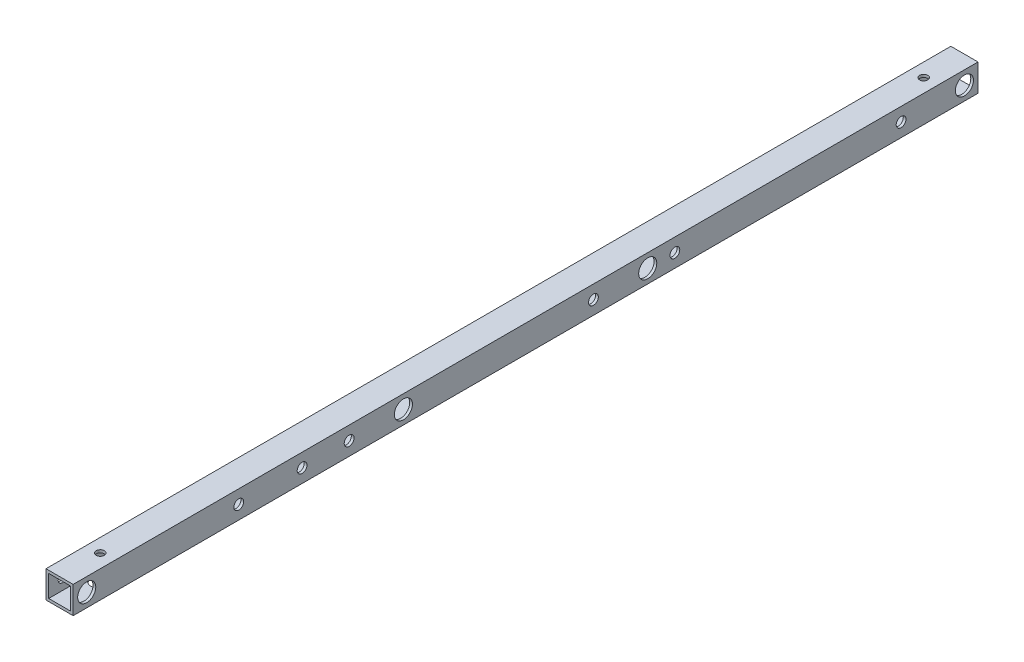
from build123d import *

# Parameters (mm, degrees)
SKETCH_1_W                  = 15
SKETCH_1_H                  = 15
SKETCH_1_W_2                = 12
SKETCH_1_H_2                = 12
EXTRUDE_1_DEPTH             = 500
SKETCH_2_R                  = 2.25
CUT_EXTRUDE_1_DEPTH         = 25
SKETCH_4_R                  = 2.25
CUT_EXTRUDE_3_DEPTH         = 20
SKETCH_5_R                  = 5
CUT_EXTRUDE_4_DEPTH         = 3.3
SKETCH_6_R                  = 5
CUT_EXTRUDE_5_DEPTH         = 3.3
HOLE_WIZARD_5_4_5_4_1_D     = 5.4
HOLE_WIZARD_10_0_10_1_D     = 10
HOLE_WIZARD_10_0_10_1_DEPTH = 1.5
HOLE_WIZARD_10_0_10_1_TIP   = 3.004303095


with BuildPart() as part:
    # ｽｹｯﾁ1 → ﾎﾞｽ - 押し出し1 (new body)
    with BuildSketch(Plane.XY):
        Rectangle(SKETCH_1_W, SKETCH_1_H)
        Rectangle(SKETCH_1_W_2, SKETCH_1_H_2, mode=Mode.SUBTRACT)
    extrude(amount=EXTRUDE_1_DEPTH)

    # ｽｹｯﾁ2 → ｶｯﾄ - 押し出し1 (cut)
    with BuildSketch(Plane(origin=(7.5, 0, 0), x_dir=(0, 0, -1), z_dir=(1, 0, 0))):
        with Locations((-492.5, 0)):
            Circle(SKETCH_2_R)
        with Locations((-7.5, 0)):
            Circle(SKETCH_2_R)
        with Locations((-317.5, 0)):
            Circle(SKETCH_2_R)
        with Locations((-182.5, 0)):
            Circle(SKETCH_2_R)
    extrude(amount=-CUT_EXTRUDE_1_DEPTH, mode=Mode.SUBTRACT)

    # ｽｹｯﾁ4 → ｶｯﾄ - 押し出し3 (cut)
    with BuildSketch(Plane(origin=(0, -7.5, 0), x_dir=(-1, 0, 0), z_dir=(0, -1, 0))):
        with Locations((0, -22.5)):
            Circle(SKETCH_4_R)
        with Locations((0, -477.5)):
            Circle(SKETCH_4_R)
    extrude(amount=-CUT_EXTRUDE_3_DEPTH, mode=Mode.SUBTRACT)

    # ｽｹｯﾁ5 → ｶｯﾄ - 押し出し4 (cut)
    with BuildSketch(Plane(origin=(7.5, 0, 0), x_dir=(0, 0, -1), z_dir=(1, 0, 0))):
        with Locations((-492.5, 0)):
            Circle(SKETCH_5_R)
        with Locations((-7.5, 0)):
            Circle(SKETCH_5_R)
        with Locations((-182.5, 0)):
            Circle(SKETCH_5_R)
        with Locations((-317.5, 0)):
            Circle(SKETCH_5_R)
    extrude(amount=-CUT_EXTRUDE_4_DEPTH, mode=Mode.SUBTRACT)

    # ｽｹｯﾁ6 → ｶｯﾄ - 押し出し5 (cut)
    with BuildSketch(Plane(origin=(0, -7.5, 0), x_dir=(1, 0, 0), z_dir=(0, 1, 0))):
        with Locations((0, -22.5)):
            Circle(SKETCH_6_R)
        with Locations((0, -477.5)):
            Circle(SKETCH_6_R)
    extrude(amount=CUT_EXTRUDE_5_DEPTH, mode=Mode.SUBTRACT)

    # Ø5.4 (5.4) 直径の穴1 (through all)
    with Locations(Plane(origin=(7.5, 0, 0), x_dir=(0, 0, -1), z_dir=(1, 0, 0))):
        with Locations((-347.5, 0), (-212.5, 0), (-167.5, 0), (-42.5, 0), (-373.5, 0), (-408.5, 0)):
            Hole(HOLE_WIZARD_5_4_5_4_1_D / 2)

    # Ø10.0 (10) 直径の穴1
    with Locations(Plane.ZY.offset(7.5)):
        with Locations((347.5, 0), (212.5, 0), (167.5, 0), (42.5, 0), (373.5, 0), (408.5, 0)):
            Hole(HOLE_WIZARD_10_0_10_1_D / 2, depth=HOLE_WIZARD_10_0_10_1_DEPTH)
            with Locations((0, 0, -(HOLE_WIZARD_10_0_10_1_DEPTH + HOLE_WIZARD_10_0_10_1_TIP / 2))):  # 118° drill point
                Cone(0, HOLE_WIZARD_10_0_10_1_D / 2, HOLE_WIZARD_10_0_10_1_TIP, mode=Mode.SUBTRACT)


solid = part.part
